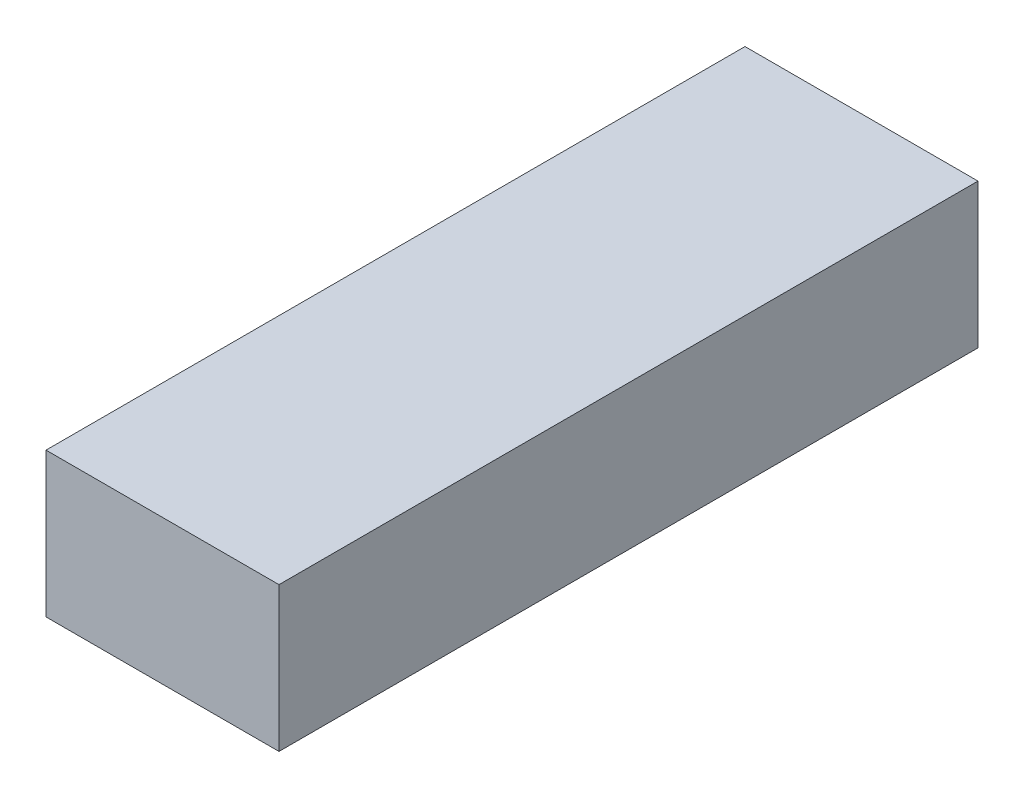
from build123d import *

# Parameters (mm, degrees)
SKETCH3_W           = 35
SKETCH3_H           = 105
BOSS_EXTRUDE1_DEPTH = 21.7


with BuildPart() as part:
    # Sketch3 → Boss-Extrude1 (new body)
    with BuildSketch(Plane(origin=(0, 0, 0), x_dir=(1, 0, 0), z_dir=(0, 1, 0))):
        with Locations((0, 52.5)):
            Rectangle(SKETCH3_W, SKETCH3_H)
    extrude(amount=BOSS_EXTRUDE1_DEPTH)


solid = part.part
